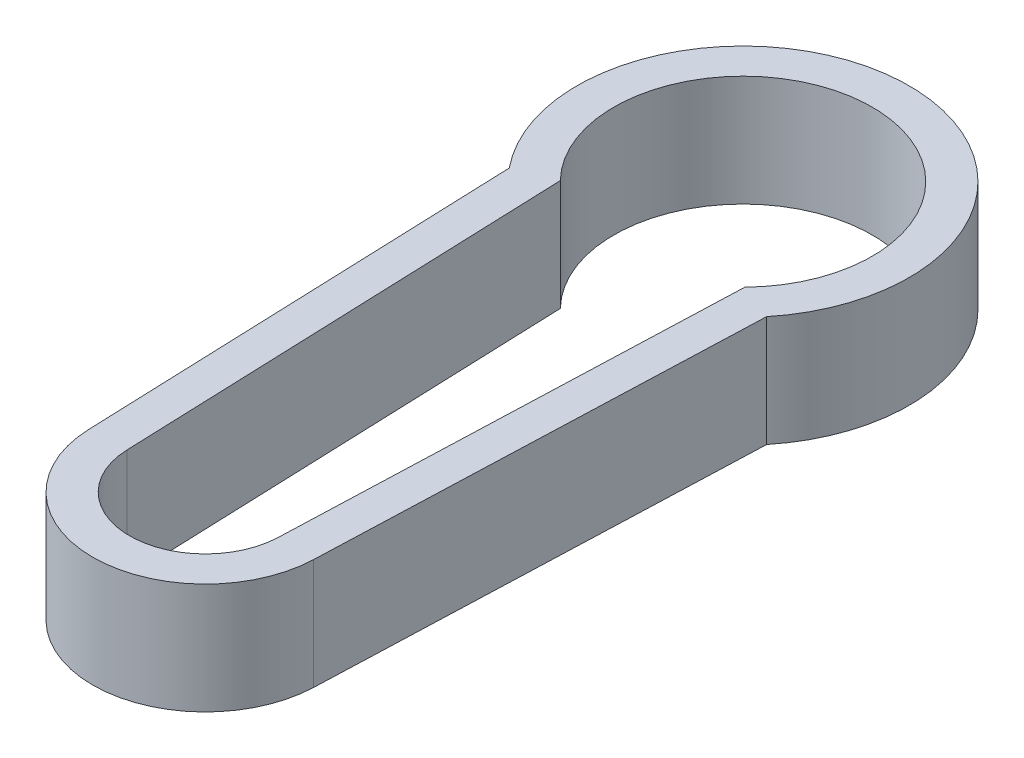
from build123d import *

# Parameters (mm, degrees)
EXTRUDE_1_DEPTH = 3


with BuildPart() as part:
    # 草圖1 → 填料-伸長1 (new body)
    with BuildSketch(Plane(origin=(0, 0, 0), x_dir=(1, 0, 0), z_dir=(0, 1, 0))):
        with BuildLine():
            Line((-3.486060765, -2.84558963), (-3.049319508, -14.678072984))
            ThreePointArc((-3.049319508, -14.678072984), (0, -17.616917452), (3.049319508, -14.678072984))
            Line((3.049319508, -14.678072984), (3.486060765, -2.84558963))
            ThreePointArc((3.486060765, -2.84558963), (0, 4.5), (-3.486060765, -2.84558963))
        make_face()
        with BuildLine():
            Line((-2.5, -2.449489743), (-2.05, -14.641187738))
            ThreePointArc((-2.05, -14.641187738), (0, -16.616917452), (2.05, -14.641187738))
            Line((2.05, -14.641187738), (2.5, -2.449489743))
            ThreePointArc((2.5, -2.449489743), (0, 3.5), (-2.5, -2.449489743))
        make_face(mode=Mode.SUBTRACT)
    extrude(amount=EXTRUDE_1_DEPTH)


solid = part.part
